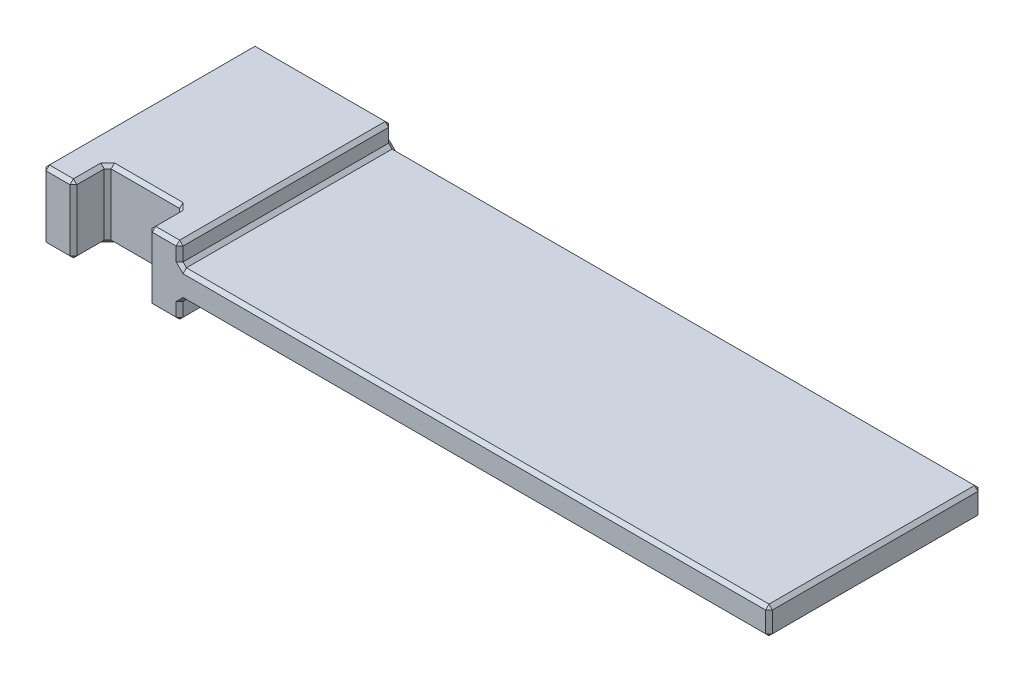
from build123d import *

# Parameters (mm, degrees)
SKETCH1_W           = 106
SKETCH1_H           = 31
BOSS_EXTRUDE1_DEPTH = 4
SKETCH2_W           = 20
SKETCH2_H           = 31
BOSS_EXTRUDE2_DEPTH = 5
SKETCH3_W           = 11
SKETCH3_H           = 5
CUT_EXTRUDE1_DEPTH  = 11
CHAMFER1_SIZE       = 0.5


with BuildPart() as part:
    # Sketch1 → Boss-Extrude1 (new body)
    with BuildSketch(Plane(origin=(0, 0, 0), x_dir=(1, 0, 0), z_dir=(0, 1, 0))):
        with Locations((53, 15.5)):
            Rectangle(SKETCH1_W, SKETCH1_H)
    extrude(amount=BOSS_EXTRUDE1_DEPTH)

    # Sketch2 → Boss-Extrude2 (add, symmetric)
    with BuildSketch(Plane(origin=(0, 2, 0), x_dir=(1, 0, 0), z_dir=(0, 1, 0))):
        with Locations((10, 15.5)):
            Rectangle(SKETCH2_W, SKETCH2_H)
    extrude(amount=BOSS_EXTRUDE2_DEPTH, both=True)

    # Sketch3 → Cut-Extrude1 (cut, through all)
    with BuildSketch(Plane(origin=(0, 7, 0), x_dir=(1, 0, 0), z_dir=(0, 1, 0))):
        with Locations((10, 2.5)):
            Rectangle(SKETCH3_W, SKETCH3_H)
    extrude(amount=-CUT_EXTRUDE1_DEPTH, mode=Mode.SUBTRACT)

    # Chamfer1
    chamfer1_edges = [part.edges().sort_by_distance(p)[0] for p in [
        (106, 4, -15.5),
        (63, 0, 0),
        (20, 0, -15.5),
        (63, 4, 0),
        (63, 4, -31),
        (20, 5.5, 0),
        (20, 4, -15.5),
        (20, 5.5, -31),
        (0, -3, -15.5),
        (2.25, -3, 0),
        (20, -1.5, 0),
        (20, -3, -15.5),
        (20, -1.5, -31),
        (10, -3, -31),
        (0, 7, -15.5),
        (2.25, 7, 0),
        (20, 7, -15.5),
        (10, 7, -31),
        (17.75, 7, 0),
        (17.75, -3, 0),
        (4.5, -3, -2.5),
        (4.5, 2, 0),
        (10, -3, -5),
        (4.5, 2, -5),
        (15.5, -3, -2.5),
        (15.5, 2, -5),
        (15.5, 2, 0),
        (4.5, 7, -2.5),
        (15.5, 7, -2.5),
        (10, 7, -5),
        (63, 0, -31),
        (106, 0, -15.5),
        (0, 2, -31),
        (106, 2, -31),
        (106, 2, 0),
        (0, 2, 0),
    ]]
    chamfer(chamfer1_edges, length=CHAMFER1_SIZE)


solid = part.part
